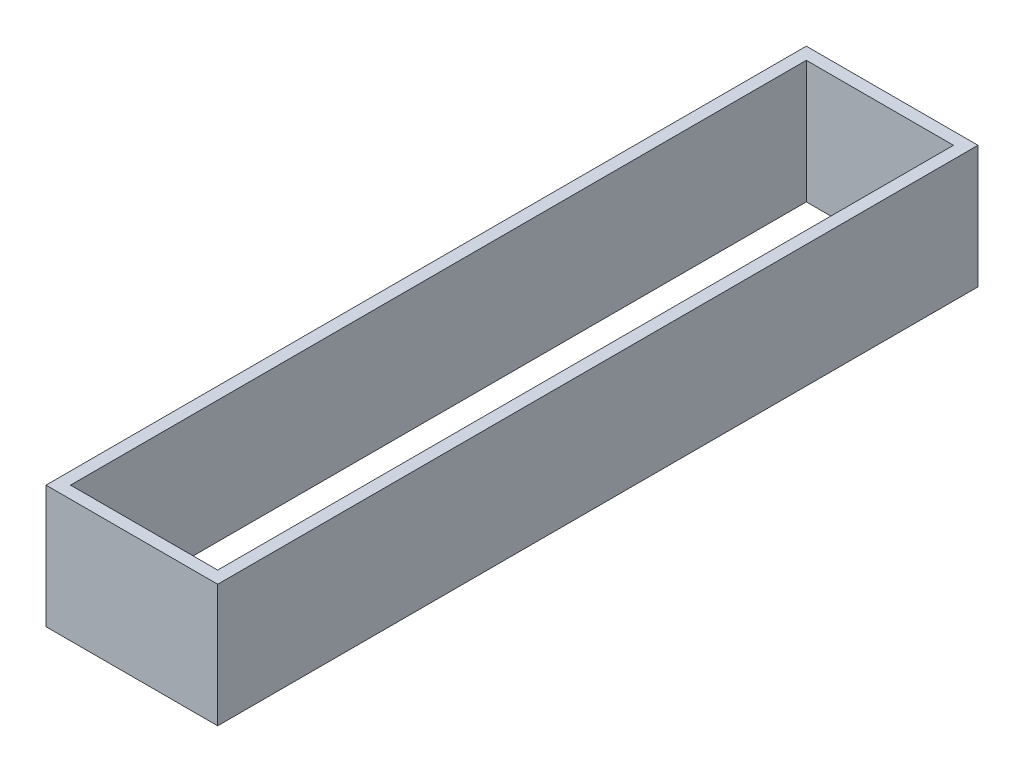
from build123d import *

# Parameters (mm, degrees)
CROQUIS1_W              = 7
CROQUIS1_H              = 31
CROQUIS1_W_2            = 6
CROQUIS1_H_2            = 30
SALIENTE_EXTRUIR2_DEPTH = 5


with BuildPart() as part:
    # Croquis1 → Saliente-Extruir2 (new body)
    with BuildSketch(Plane(origin=(0, 0, 0), x_dir=(1, 0, 0), z_dir=(0, 1, 0))):
        with Locations((-5.976, 8.912)):
            Rectangle(CROQUIS1_W, CROQUIS1_H)
        with Locations((-5.976, 8.912)):
            Rectangle(CROQUIS1_W_2, CROQUIS1_H_2, mode=Mode.SUBTRACT)
    extrude(amount=SALIENTE_EXTRUIR2_DEPTH)


solid = part.part
